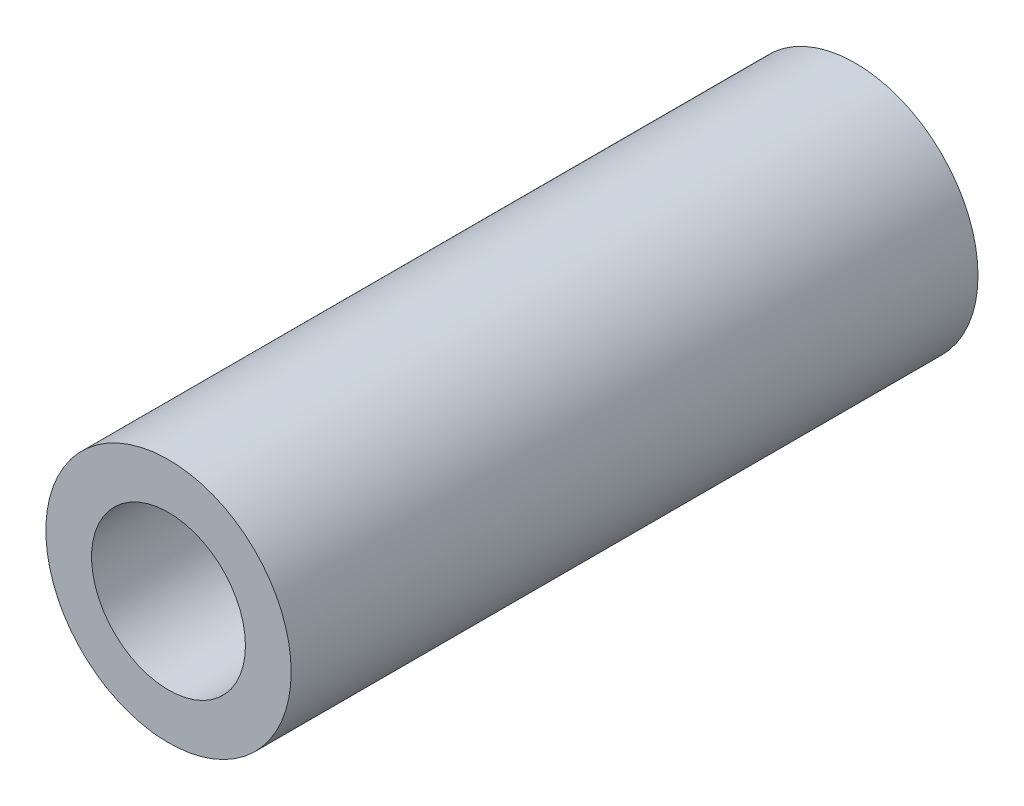
from build123d import *

# Parameters (mm, degrees)
SKETCH1_R           = 3.96875
SKETCH1_R_2         = 2.4892
BOSS_EXTRUDE1_DEPTH = 22.225


with BuildPart() as part:
    # Sketch1 → Boss-Extrude1 (new body)
    with BuildSketch(Plane.XY):
        Circle(SKETCH1_R)
        Circle(SKETCH1_R_2, mode=Mode.SUBTRACT)
    extrude(amount=BOSS_EXTRUDE1_DEPTH)


solid = part.part
